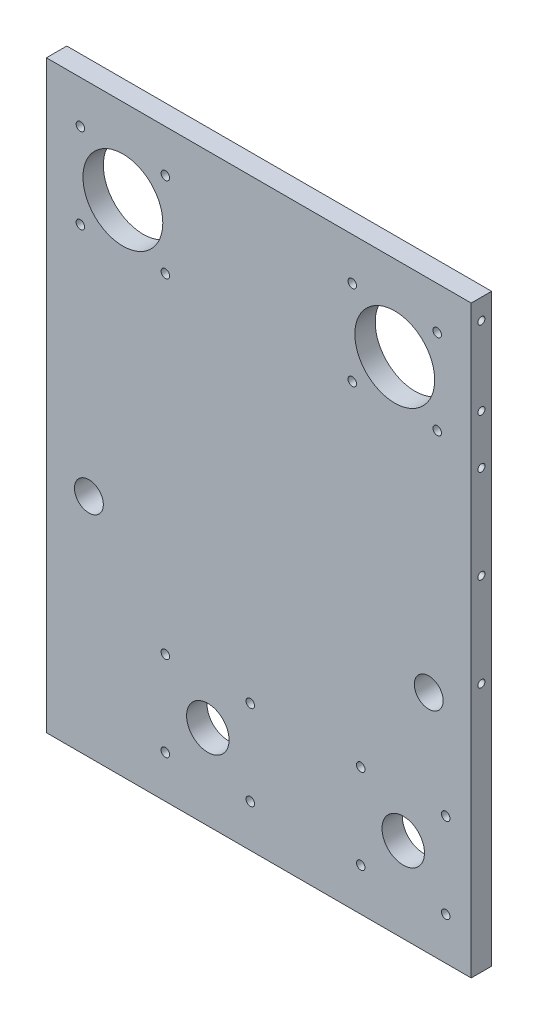
from build123d import *

# Parameters (mm, degrees)
SKETCH1_W                  = 250
SKETCH1_H                  = 344
SKETCH1_R                  = 23.5
SKETCH1_R_2                = 8.5
SKETCH1_R_3                = 12.5
BOSS_EXTRUDE1_DEPTH        = 12
M5_TAPPED_HOLE1_AT_2_COUNT = 2
M5_TAPPED_HOLE1_AT_2_PITCH = 46
M6_TAPPED_HOLE1_D          = 5
M5_TAPPED_HOLE2_D          = 4.2
M5_TAPPED_HOLE2_DEPTH      = 15
M5_TAPPED_HOLE2_TIP        = 1.2618073
M5_TAPPED_HOLE3_AT_2_COUNT = 2
M5_TAPPED_HOLE3_AT_2_PITCH = 55
M5_TAPPED_HOLE3_AT_3_COUNT = 2
M5_TAPPED_HOLE3_AT_3_PITCH = 110


with BuildPart() as part:
    # Sketch1 → Boss-Extrude1 (new body)
    with BuildSketch(Plane.XY):
        with Locations((0, 122)):
            Rectangle(SKETCH1_W, SKETCH1_H)
        with Locations((-80, 244)):
            Circle(SKETCH1_R, mode=Mode.SUBTRACT)
        with Locations((80, 244)):
            Circle(SKETCH1_R, mode=Mode.SUBTRACT)
        with Locations((-100, 83)):
            Circle(SKETCH1_R_2, mode=Mode.SUBTRACT)
        with Locations((100, 83)):
            Circle(SKETCH1_R_2, mode=Mode.SUBTRACT)
        with Locations((-30, 0)):
            Circle(SKETCH1_R_3, mode=Mode.SUBTRACT)
        with Locations((85, 0)):
            Circle(SKETCH1_R_3, mode=Mode.SUBTRACT)
    extrude(amount=BOSS_EXTRUDE1_DEPTH)

    # Sketch5 → M5 Tapped Hole1 (revolve, cut)
    with BuildSketch(Plane(origin=(-125, 282, 6), x_dir=(0, 0, 1), z_dir=(0, 1, 0))):
        Polygon((0, 0), (0, 16.2618073), (2.1, 15), (2.1, 0), align=None)
    m5_tapped_hole1 = revolve(axis=Axis((-131.35, 282, 6), (1, 0, 0)), mode=Mode.SUBTRACT)

    # M5 Tapped Hole1 at 2: M5 Tapped Hole1 ×2
    with Locations(*[(0, -i * M5_TAPPED_HOLE1_AT_2_PITCH, 0) for i in range(1, M5_TAPPED_HOLE1_AT_2_COUNT)]):
        add(m5_tapped_hole1, mode=Mode.SUBTRACT)

    # Mirror1: M5 Tapped Hole1 across plane
    add(m5_tapped_hole1.mirror(Plane(origin=(0, 0, 0), x_dir=(0, 0, 1), z_dir=(1, 0, 0))), mode=Mode.SUBTRACT)

    # Mirror1 copy 1 sketch → Mirror1 copy 1 (revolve, cut)
    with BuildSketch(Plane(origin=(125, 236, 6), x_dir=(0, 0, 1), z_dir=(0, 1, 0))):
        Polygon((0, 0), (0, -16.2618073), (2.1, -15), (2.1, 0), align=None)
    revolve(axis=Axis((131.35, 236, 6), (1, 0, 0)), mode=Mode.SUBTRACT)

    # M6 Tapped Hole1 (through all)
    with Locations(Plane.XY.offset(12)):
        with Locations((-105, 269), (-55, 269), (-55, 219), (-105, 219), (55, 219), (105, 219), (105, 269), (55, 269), (-55, 25), (-5, 25), (-5, -25), (-55, -25), (60, 25), (110, 25), (110, -25), (60, -25)):
            Hole(M6_TAPPED_HOLE1_D / 2)

    # M5 Tapped Hole2
    with Locations(Plane(origin=(0, -50, 0), x_dir=(-1, 0, 0), z_dir=(0, -1, 0))):
        with Locations((-113, -6), (-67, -6), (67, -6), (113, -6)):
            Hole(M5_TAPPED_HOLE2_D / 2, depth=M5_TAPPED_HOLE2_DEPTH)
            with Locations((0, 0, -(M5_TAPPED_HOLE2_DEPTH + M5_TAPPED_HOLE2_TIP / 2))):  # 118° drill point
                Cone(0, M5_TAPPED_HOLE2_D / 2, M5_TAPPED_HOLE2_TIP, mode=Mode.SUBTRACT)

    # Sketch19 → M5 Tapped Hole3 (revolve, cut)
    with BuildSketch(Plane(origin=(125, 97, 6), x_dir=(0, 0, -1), z_dir=(0, 1, 0))):
        Polygon((0, 0), (0, 16.2618073), (2.1, 15), (2.1, 0), align=None)
    m5_tapped_hole3 = revolve(axis=Axis((131.35, 97, 6), (-1, 0, 0)), mode=Mode.SUBTRACT)

    # M5 Tapped Hole3 at 2: M5 Tapped Hole3 ×2
    with Locations(*[(0, i * M5_TAPPED_HOLE3_AT_2_PITCH, 0) for i in range(1, M5_TAPPED_HOLE3_AT_2_COUNT)]):
        add(m5_tapped_hole3, mode=Mode.SUBTRACT)

    # M5 Tapped Hole3 at 3: M5 Tapped Hole3 ×2
    with Locations(*[(0, i * M5_TAPPED_HOLE3_AT_3_PITCH, 0) for i in range(1, M5_TAPPED_HOLE3_AT_3_COUNT)]):
        add(m5_tapped_hole3, mode=Mode.SUBTRACT)

    # Mirror2: M5 Tapped Hole3 across plane
    add(m5_tapped_hole3.mirror(Plane(origin=(0, 0, 0), x_dir=(0, 0, 1), z_dir=(1, 0, 0))), mode=Mode.SUBTRACT)

    # Mirror2 copy 1 sketch → Mirror2 copy 1 (revolve, cut)
    with BuildSketch(Plane(origin=(-125, 152, 6), x_dir=(0, 0, -1), z_dir=(0, 1, 0))):
        Polygon((0, 0), (0, -16.2618073), (2.1, -15), (2.1, 0), align=None)
    revolve(axis=Axis((-131.35, 152, 6), (-1, 0, 0)), mode=Mode.SUBTRACT)

    # Mirror2 copy 2 sketch → Mirror2 copy 2 (revolve, cut)
    with BuildSketch(Plane(origin=(-125, 207, 6), x_dir=(0, 0, -1), z_dir=(0, 1, 0))):
        Polygon((0, 0), (0, -16.2618073), (2.1, -15), (2.1, 0), align=None)
    revolve(axis=Axis((-131.35, 207, 6), (-1, 0, 0)), mode=Mode.SUBTRACT)


solid = part.part
